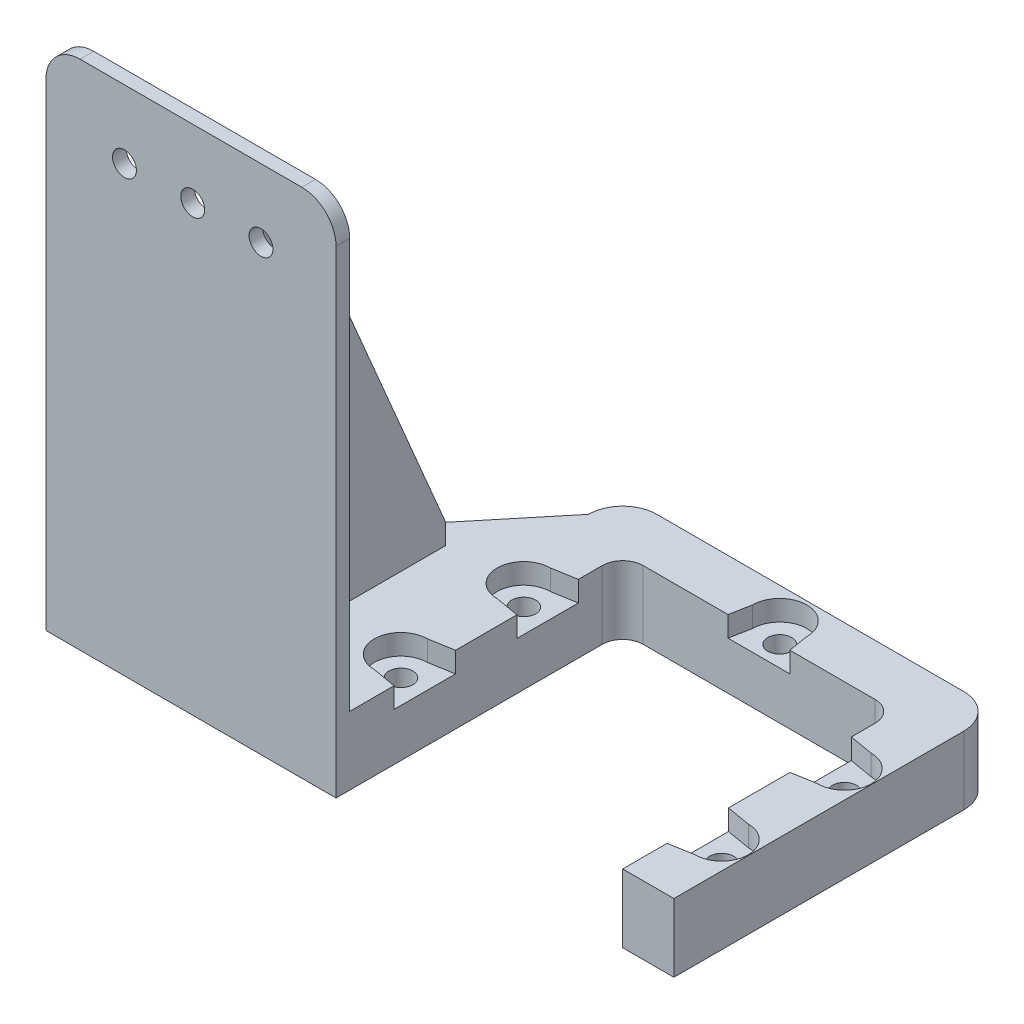
from build123d import *

# Parameters (mm, degrees)
BOSS_EXTRUDE1_DEPTH = 10
SKETCH2_R           = 1.75
CUT_EXTRUDE1_DEPTH  = 15.5
CUT_EXTRUDE2_DEPTH  = 3
CUT_EXTRUDE7_DEPTH  = 3
BOSS_EXTRUDE2_DEPTH = 10
SKETCH11_W          = 42.5
SKETCH11_H          = 75
BOSS_EXTRUDE3_DEPTH = 2
SKETCH12_W          = 3
SKETCH12_H          = 28
BOSS_EXTRUDE4_DEPTH = 62
CHAMFER1_SIZE       = 25
CHAMFER1_SIZE2      = 58.896309146
FILLET1_R           = 5
SKETCH13_R          = 1.75
CUT_EXTRUDE8_DEPTH  = 3


with BuildPart() as part:
    # Sketch1 → Boss-Extrude1 (new body)
    with BuildSketch(Plane(origin=(0, 0, 0), x_dir=(1, 0, 0), z_dir=(0, 1, 0))):
        with BuildLine():
            Line((-20, -20), (-27.5, -20))
            Line((-27.5, -20), (-27.5, 22.5))
            ThreePointArc((-27.5, 22.5), (-26.035533906, 26.035533906), (-22.5, 27.5))
            Line((-22.5, 27.5), (22.5, 27.5))
            ThreePointArc((22.5, 27.5), (26.035533906, 26.035533906), (27.5, 22.5))
            Line((27.5, 22.5), (27.5, -20))
            Line((27.5, -20), (20, -20))
            Line((20, -20), (20, 17))
            ThreePointArc((20, 17), (19.121320344, 19.121320344), (17, 20))
            Line((17, 20), (-17, 20))
            ThreePointArc((-17, 20), (-19.121320344, 19.121320344), (-20, 17))
            Line((-20, 17), (-20, -20))
        make_face()
    extrude(amount=BOSS_EXTRUDE1_DEPTH)

    # Sketch2 → Cut-Extrude1 (cut)
    with BuildSketch(Plane(origin=(0, 10, 0), x_dir=(1, 0, 0), z_dir=(0, 1, 0))):
        with Locations((-23.5, -9)):
            Circle(SKETCH2_R)
        with Locations((23.5, -9)):
            Circle(SKETCH2_R)
        with Locations((0, 23)):
            Circle(SKETCH2_R)
        with Locations((-23.5, 9)):
            Circle(SKETCH2_R)
        with Locations((23.5, 9)):
            Circle(SKETCH2_R)
    extrude(amount=-CUT_EXTRUDE1_DEPTH, mode=Mode.SUBTRACT)

    # Sketch3 → Cut-Extrude2 (cut)
    with BuildSketch(Plane.XZ):
        Polygon((-20.6, 7.325684219), (-20.6, 10.674315781), (-23.5, 12.348631561), (-26.4, 10.674315781), (-26.4, 7.325684219), (-23.5, 5.651368439), align=None)
        Polygon((23.4996681, 5.651368455), (26.399834036, 7.325396794), (26.400165936, 10.674028339), (23.5003319, 12.348631545), (20.600165964, 10.674603206), (20.599834064, 7.325971661), align=None)
        Polygon((3.348631561, -23), (1.674315781, -20.1), (-1.674315781, -20.1), (-3.348631561, -23), (-1.674315781, -25.9), (1.674315781, -25.9), align=None)
        Polygon((-23.4996681, -5.651368455), (-26.399834036, -7.325396794), (-26.400165936, -10.674028339), (-23.5003319, -12.348631545), (-20.600165964, -10.674603206), (-20.599834064, -7.325971661), align=None)
        Polygon((23.4996681, -5.651368455), (20.599834064, -7.325971661), (20.600165964, -10.674603206), (23.5003319, -12.348631545), (26.400165936, -10.674028339), (26.399834036, -7.325396794), align=None)
    extrude(amount=-CUT_EXTRUDE2_DEPTH, mode=Mode.SUBTRACT)

    # Sketch8 → Cut-Extrude7 (cut)
    with BuildSketch(Plane(origin=(0, 10, 0), x_dir=(1, 0, 0), z_dir=(0, 1, 0))):
        with BuildLine():
            Line((-4, 23), (-4.57455059, 20))
            Line((-4.57455059, 20), (4.478329848, 20))
            Line((4.478329848, 20), (4, 23))
            ThreePointArc((4, 23), (0, 27), (-4, 23))
        make_face()
        with BuildLine():
            Line((23.5, 12.9), (20, 13.5))
            Line((20, 13.5), (20, 4.5))
            Line((20, 4.5), (23.5, 5.1))
            ThreePointArc((23.5, 5.1), (27.4, 9), (23.5, 12.9))
        make_face()
        with BuildLine():
            Line((23.5, -5.1), (20, -4.5))
            Line((20, -4.5), (20, -13.5))
            Line((20, -13.5), (23.5, -12.9))
            ThreePointArc((23.5, -12.9), (27.4, -9), (23.5, -5.1))
        make_face()
        with BuildLine():
            Line((-23.5, -12.9), (-20, -13.5))
            Line((-20, -13.5), (-20, -4.5))
            Line((-20, -4.5), (-23.5, -5.1))
            ThreePointArc((-23.5, -5.1), (-27.4, -9), (-23.5, -12.9))
        make_face()
        with BuildLine():
            Line((-23.5, 12.9), (-20, 13.5))
            Line((-20, 13.5), (-20, 4.5))
            Line((-20, 4.5), (-23.5, 5.1))
            ThreePointArc((-23.5, 5.1), (-27.4, 9), (-23.5, 12.9))
        make_face()
    extrude(amount=-CUT_EXTRUDE7_DEPTH, mode=Mode.SUBTRACT)

    # Sketch10 → Boss-Extrude2 (add)
    with BuildSketch(Plane(origin=(0, 0, 0), x_dir=(1, 0, 0), z_dir=(0, 1, 0))):
        Polygon((-27.5, 22.5), (-62.5, -20), (-27.5, -20), align=None)
    extrude(amount=BOSS_EXTRUDE2_DEPTH)

    # Sketch11 → Boss-Extrude3 (add)
    with BuildSketch(Plane.XY.offset(20)):
        with Locations((-41.25, 37.5)):
            Rectangle(SKETCH11_W, SKETCH11_H)
    extrude(amount=BOSS_EXTRUDE3_DEPTH)

    # Sketch12 → Boss-Extrude4 (add)
    with BuildSketch(Plane(origin=(0, 10, 0), x_dir=(1, 0, 0), z_dir=(0, 1, 0))):
        with Locations((-35.5, -6)):
            Rectangle(SKETCH12_W, SKETCH12_H)
    extrude(amount=BOSS_EXTRUDE4_DEPTH)

    # Chamfer1
    chamfer1_edges = [part.edges().sort_by_distance(p)[0] for p in [
        (-35.5, 72, -8),
    ]]
    chamfer1_side = [part.faces().sort_by_distance(p)[0] for p in [
        (-35.5, 72, 6),
    ]]
    chamfer(chamfer1_edges, length=CHAMFER1_SIZE, length2=CHAMFER1_SIZE2, reference=chamfer1_side[0])

    # Fillet1
    fillet1_edges = [part.edges().sort_by_distance(p)[0] for p in [
        (-62.5, 75, 21),
        (-20, 75, 21),
    ]]
    fillet(fillet1_edges, radius=FILLET1_R)

    # Sketch13 → Cut-Extrude8 (cut, through all)
    with BuildSketch(Plane(origin=(0, 0, 20), x_dir=(-1, 0, 0), z_dir=(0, 0, -1))):
        with Locations((31, 65)):
            Circle(SKETCH13_R)
        with Locations((41, 65)):
            Circle(SKETCH13_R)
        with Locations((51, 65)):
            Circle(SKETCH13_R)
    extrude(amount=-CUT_EXTRUDE8_DEPTH, mode=Mode.SUBTRACT)


solid = part.part
